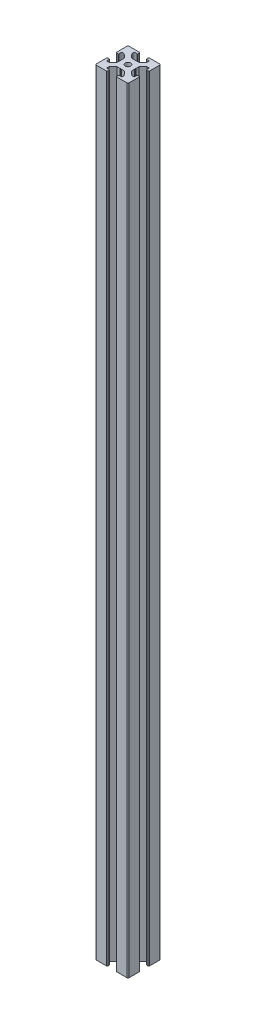
from build123d import *

# Parameters (mm, degrees)
BOSS_EXTRUDE1_DEPTH = 710
FILLET1_R           = 1
SKETCH4_R           = 2.5
CUT_EXTRUDE1_DEPTH  = 711
FILLET2_R           = 0.5


with BuildPart() as part:
    # Sketch3 → Boss-Extrude1 (new body)
    with BuildSketch(Plane(origin=(0, 0, 0), x_dir=(1, 0, 0), z_dir=(0, 1, 0))):
        with BuildLine():
            Line((11, 27.75), (11, 29.5))
            ThreePointArc((11, 29.5), (10.646446609, 29.646446609), (10.5, 30))
            Line((10.5, 30), (0, 30))
            Line((0, 30), (0, 19.5))
            ThreePointArc((0, 19.5), (0.353553391, 19.353553391), (0.5, 19))
            Line((0.5, 19), (2.25, 19))
            Line((2.25, 19), (2.25, 22))
            Line((2.25, 22), (4.5, 22))
            Line((4.5, 22), (8.25, 18.5))
            Line((8.25, 18.5), (8.25, 15.5))
            Line((8.25, 15.5), (8.75, 15))
            Line((8.75, 15), (8.25, 14.5))
            Line((8.25, 14.5), (8.25, 11.5))
            Line((8.25, 11.5), (4.5, 8))
            Line((4.5, 8), (2.25, 8))
            Line((2.25, 8), (2.25, 11))
            Line((2.25, 11), (0.5, 11))
            ThreePointArc((0.5, 11), (0.353553391, 10.646446609), (0, 10.5))
            Line((0, 10.5), (0, 0))
            Line((0, 0), (10.5, 0))
            ThreePointArc((10.5, 0), (10.646446609, 0.353553391), (11, 0.5))
            Line((11, 0.5), (11, 2.25))
            Line((11, 2.25), (8, 2.25))
            Line((8, 2.25), (8, 4.5))
            Line((8, 4.5), (11.5, 8.25))
            Line((11.5, 8.25), (14.5, 8.25))
            Line((14.5, 8.25), (15, 8.75))
            Line((15, 8.75), (15.5, 8.25))
            Line((15.5, 8.25), (18.5, 8.25))
            Line((18.5, 8.25), (22, 4.5))
            Line((22, 4.5), (22, 2.25))
            Line((22, 2.25), (19, 2.25))
            Line((19, 2.25), (19, 0.5))
            ThreePointArc((19, 0.5), (19.353553391, 0.353553391), (19.5, 0))
            Line((19.5, 0), (30, 0))
            Line((30, 0), (30, 10.5))
            ThreePointArc((30, 10.5), (29.646446609, 10.646446609), (29.5, 11))
            Line((29.5, 11), (27.75, 11))
            Line((27.75, 11), (27.75, 8))
            Line((27.75, 8), (25.5, 8))
            Line((25.5, 8), (21.75, 11.5))
            Line((21.75, 11.5), (21.75, 14.5))
            Line((21.75, 14.5), (21.25, 15))
            Line((21.25, 15), (21.75, 15.5))
            Line((21.75, 15.5), (21.75, 18.5))
            Line((21.75, 18.5), (25.5, 22))
            Line((25.5, 22), (27.75, 22))
            Line((27.75, 22), (27.75, 19))
            Line((27.75, 19), (29.5, 19))
            ThreePointArc((29.5, 19), (29.646446609, 19.353553391), (30, 19.5))
            Line((30, 19.5), (30, 30))
            Line((30, 30), (19.5, 30))
            ThreePointArc((19.5, 30), (19.353553391, 29.646446609), (19, 29.5))
            Line((19, 29.5), (19, 27.75))
            Line((19, 27.75), (22, 27.75))
            Line((22, 27.75), (22, 25.5))
            Line((22, 25.5), (18.5, 21.75))
            Line((18.5, 21.75), (15.5, 21.75))
            Line((15.5, 21.75), (15, 21.25))
            Line((15, 21.25), (14.5, 21.75))
            Line((14.5, 21.75), (11.5, 21.75))
            Line((11.5, 21.75), (8, 25.5))
            Line((8, 25.5), (8, 27.75))
            Line((8, 27.75), (11, 27.75))
        make_face()
    extrude(amount=BOSS_EXTRUDE1_DEPTH)

    # Fillet1
    fillet1_edges = [part.edges().sort_by_distance(p)[0] for p in [
        (30, 355, 0),
        (0, 355, 0),
        (0, 355, -30),
        (30, 355, -30),
    ]]
    fillet(fillet1_edges, radius=FILLET1_R)

    # Sketch4 → Cut-Extrude1 (cut, through all)
    with BuildSketch(Plane(origin=(0, 710, 0), x_dir=(1, 0, 0), z_dir=(0, 1, 0))):
        with Locations((15, 15)):
            Circle(SKETCH4_R)
    extrude(amount=-CUT_EXTRUDE1_DEPTH, mode=Mode.SUBTRACT)

    # Fillet2
    fillet2_edges = [part.edges().sort_by_distance(p)[0] for p in [
        (27.75, 355, -19),
        (27.75, 355, -22),
        (21.75, 355, -15.5),
        (21.75, 355, -14.5),
        (27.75, 355, -8),
        (27.75, 355, -11),
        (19, 355, -2.25),
        (22, 355, -2.25),
        (15.5, 355, -8.25),
        (14.5, 355, -8.25),
        (8, 355, -2.25),
        (11, 355, -2.25),
        (2.25, 355, -11),
        (2.25, 355, -8),
        (8.25, 355, -14.5),
        (8.25, 355, -15.5),
        (2.25, 355, -22),
        (2.25, 355, -19),
        (11, 355, -27.75),
        (8, 355, -27.75),
        (14.5, 355, -21.75),
        (15.5, 355, -21.75),
        (22, 355, -27.75),
        (19, 355, -27.75),
    ]]
    fillet(fillet2_edges, radius=FILLET2_R)


solid = part.part
